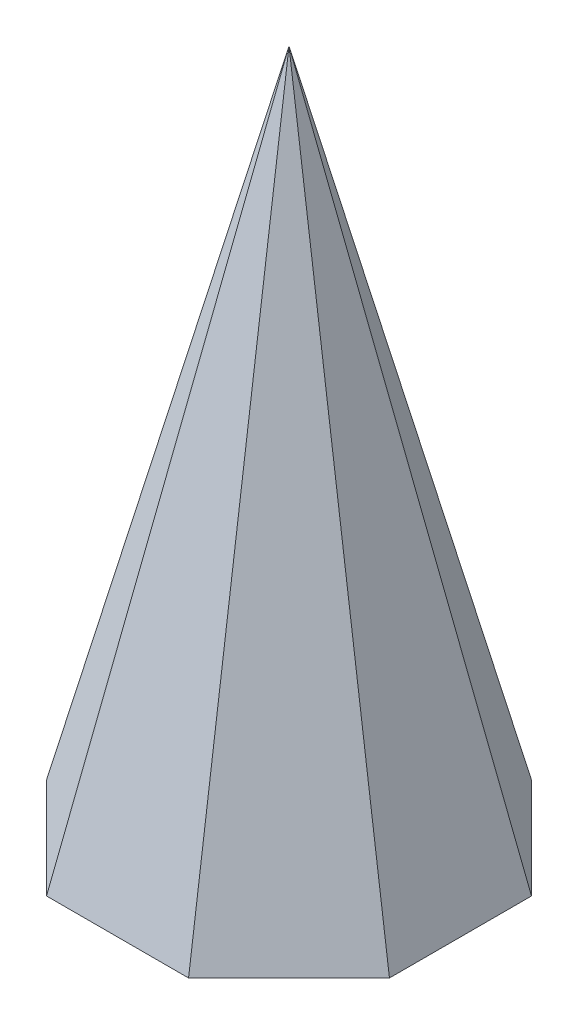
from build123d import *


with BuildPart() as part:
    # Sketch1 → Loft1 section 0
    with BuildSketch(Plane(origin=(0, 0, 0), x_dir=(1, 0, 0), z_dir=(0, 1, 0)), mode=Mode.PRIVATE) as loft1_s0:
        Polygon((2.071067812, -5), (5, -2.071067812), (5, 2.071067812), (2.071067812, 5), (-2.071067812, 5), (-5, 2.071067812), (-5, -2.071067812), (-2.071067812, -5), align=None)
    loft([Vertex(0, 20, 0), loft1_s0.sketch])


solid = part.part
